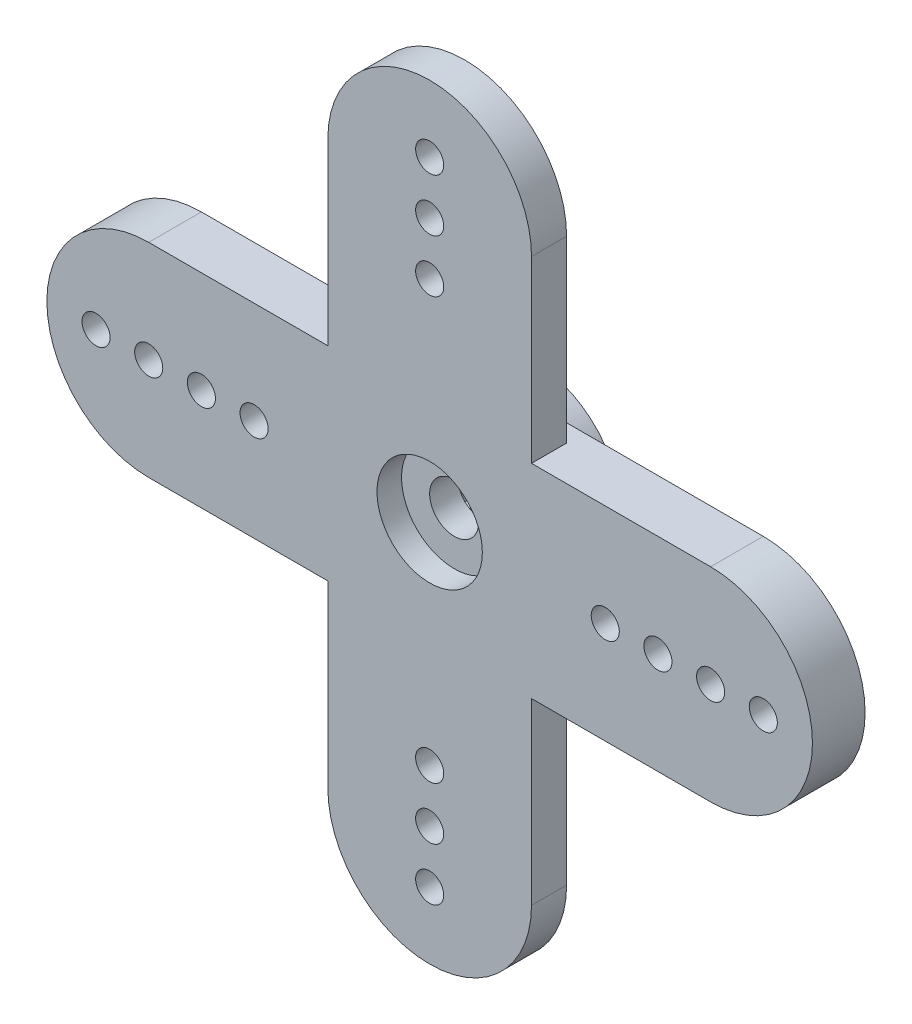
from build123d import *

# Parameters (mm, degrees)
ESQUISSE1_R                  = 5
BOSS_EXTRU_1_DEPTH           = 2.9
BOSS_EXTRU_2_DEPTH           = 3
BOSS_EXTRU_3_DEPTH           = 2
ESQUISSE4_R                  = 0.8
ENL_V_MAT_EXTRU_1_DEPTH      = 6.9
ESQUISSE5_R                  = 0.8
ENL_V_MAT_EXTRU_2_DEPTH      = 6.9
R_P_TITION_CIRCULAIRE1_COUNT = 2
ESQUISSE6_R                  = 3
ENL_V_MAT_EXTRU_3_DEPTH      = 1.4
ESQUISSE7_R                  = 1.4
ENL_V_MAT_EXTRU_4_DEPTH      = 5.5


with BuildPart() as part:
    # Esquisse1 → Boss.-Extru.1 (new body)
    with BuildSketch(Plane.XY):
        Circle(ESQUISSE1_R)
        Polygon((2.011577371, -1.550856692), (2.011577371, -2.011577371), (1.550856692, -2.011577371), (1.541643286, -2.018647066), (1.4224, -2.463669069), (0.977377998, -2.344425783), (0.966648759, -2.348869979), (0.73628842, -2.747865791), (0.337292608, -2.517505451), (0.325778716, -2.519021284), (0, -2.8448), (-0.325778716, -2.519021284), (-0.337292608, -2.517505451), (-0.73628842, -2.747865791), (-0.966648759, -2.348869979), (-0.977377998, -2.344425783), (-1.4224, -2.463669069), (-1.541643286, -2.018647066), (-1.550856692, -2.011577371), (-2.011577371, -2.011577371), (-2.011577371, -1.550856692), (-2.018647066, -1.541643286), (-2.463669069, -1.4224), (-2.344425783, -0.977377998), (-2.348869979, -0.966648759), (-2.747865791, -0.73628842), (-2.517505451, -0.337292608), (-2.519021284, -0.325778716), (-2.8448, 0), (-2.519021284, 0.325778716), (-2.517505451, 0.337292608), (-2.747865791, 0.73628842), (-2.348869979, 0.966648759), (-2.344425783, 0.977377998), (-2.463669069, 1.4224), (-2.018647066, 1.541643286), (-2.011577371, 1.550856692), (-2.011577371, 2.011577371), (-1.550856692, 2.011577371), (-1.541643286, 2.018647066), (-1.4224, 2.463669069), (-0.977377998, 2.344425783), (-0.966648759, 2.348869979), (-0.73628842, 2.747865791), (-0.337292608, 2.517505451), (-0.325778716, 2.519021284), (0, 2.8448), (0.325778716, 2.519021284), (0.337292608, 2.517505451), (0.73628842, 2.747865791), (0.966648759, 2.348869979), (0.977377998, 2.344425783), (1.4224, 2.463669069), (1.541643286, 2.018647066), (1.550856692, 2.011577371), (2.011577371, 2.011577371), (2.011577371, 1.550856692), (2.018647066, 1.541643286), (2.463669069, 1.4224), (2.344425783, 0.977377998), (2.348869979, 0.966648759), (2.747865791, 0.73628842), (2.517505451, 0.337292608), (2.519021284, 0.325778716), (2.8448, 0), (2.519021284, -0.325778716), (2.517505451, -0.337292608), (2.747865791, -0.73628842), (2.348869979, -0.966648759), (2.344425783, -0.977377998), (2.463669069, -1.4224), (2.018647066, -1.541643286), align=None, mode=Mode.SUBTRACT)
    extrude(amount=BOSS_EXTRU_1_DEPTH)

    # Esquisse2 → Boss.-Extru.2 (add)
    with BuildSketch(Plane.XY.offset(2.9)):
        with BuildLine():
            Line((-16, 5.8), (16, 5.8))
            ThreePointArc((16, 5.8), (21.8, 0), (16, -5.8))
            Line((16, -5.8), (-16, -5.8))
            ThreePointArc((-16, -5.8), (-21.8, 0), (-16, 5.8))
        make_face()
    extrude(amount=BOSS_EXTRU_2_DEPTH)

    # Esquisse3 → Boss.-Extru.3 (add)
    with BuildSketch(Plane.XY.offset(5.9)):
        with BuildLine():
            Line((5.8, 16), (5.8, -16))
            ThreePointArc((5.8, -16), (0, -21.8), (-5.8, -16))
            Line((-5.8, -16), (-5.8, 16))
            ThreePointArc((-5.8, 16), (0, 21.8), (5.8, 16))
        make_face()
    extrude(amount=-BOSS_EXTRU_3_DEPTH)

    # Esquisse4 → Enlèv. mat.-Extru.1 (cut, through all)
    with BuildSketch(Plane.XY.offset(5.9)):
        with Locations((-10, 0)):
            Circle(ESQUISSE4_R)
        with Locations((-13, 0)):
            Circle(ESQUISSE4_R)
        with Locations((-16, 0)):
            Circle(ESQUISSE4_R)
        with Locations((-19, 0)):
            Circle(ESQUISSE4_R)
    enl_v_mat_extru_1 = extrude(amount=-ENL_V_MAT_EXTRU_1_DEPTH, mode=Mode.SUBTRACT)

    # Esquisse5 → Enlèv. mat.-Extru.2 (cut, through all)
    with BuildSketch(Plane.XY.offset(5.9)):
        with Locations((0, 12)):
            Circle(ESQUISSE5_R)
        with Locations((0, 15)):
            Circle(ESQUISSE5_R)
        with Locations((0, 18)):
            Circle(ESQUISSE5_R)
    enl_v_mat_extru_2 = extrude(amount=-ENL_V_MAT_EXTRU_2_DEPTH, mode=Mode.SUBTRACT)

    # Répétition circulaire1: Enlèv. mat.-Extru.1, Enlèv. mat.-Extru.2 ×2 about axis
    r_p_tition_circulaire1_axis = Axis((0, 0, 0), (0, 0, 1))
    for i in range(1, R_P_TITION_CIRCULAIRE1_COUNT):
        add(enl_v_mat_extru_1.rotate(r_p_tition_circulaire1_axis, i * 360 / R_P_TITION_CIRCULAIRE1_COUNT), mode=Mode.SUBTRACT)
        add(enl_v_mat_extru_2.rotate(r_p_tition_circulaire1_axis, i * 360 / R_P_TITION_CIRCULAIRE1_COUNT), mode=Mode.SUBTRACT)

    # Esquisse6 → Enlèv. mat.-Extru.3 (cut)
    with BuildSketch(Plane.XY.offset(5.9)):
        Circle(ESQUISSE6_R)
    extrude(amount=-ENL_V_MAT_EXTRU_3_DEPTH, mode=Mode.SUBTRACT)

    # Esquisse7 → Enlèv. mat.-Extru.4 (cut, through all)
    with BuildSketch(Plane.XY.offset(4.5)):
        Circle(ESQUISSE7_R)
    extrude(amount=-ENL_V_MAT_EXTRU_4_DEPTH, mode=Mode.SUBTRACT)


solid = part.part
